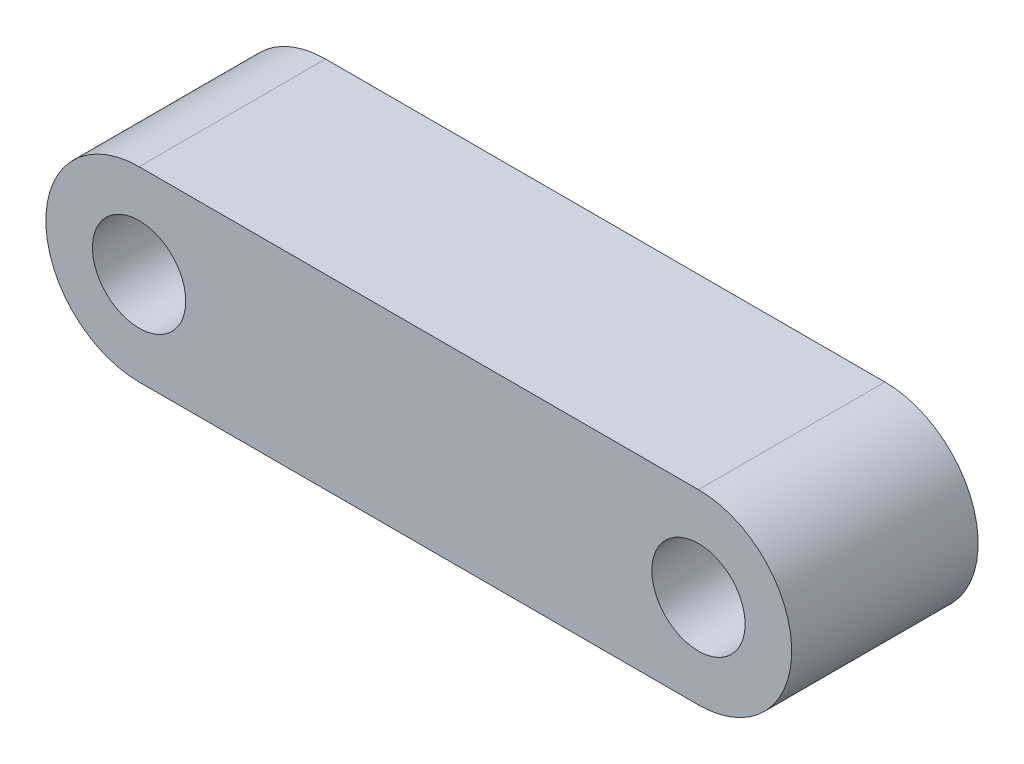
from build123d import *

# Parameters (mm, degrees)
SKETCH1_R           = 2.5
BOSS_EXTRUDE1_DEPTH = 10


with BuildPart() as part:
    # Sketch1 → Boss-Extrude1 (new body)
    with BuildSketch(Plane.XY):
        with BuildLine():
            Line((-15, 5), (15, 5))
            ThreePointArc((15, 5), (20, 0), (15, -5))
            Line((15, -5), (-15, -5))
            ThreePointArc((-15, -5), (-20, 0), (-15, 5))
        make_face()
        with Locations((-15, 0)):
            Circle(SKETCH1_R, mode=Mode.SUBTRACT)
        with Locations((15, 0)):
            Circle(SKETCH1_R, mode=Mode.SUBTRACT)
    extrude(amount=BOSS_EXTRUDE1_DEPTH)


solid = part.part
